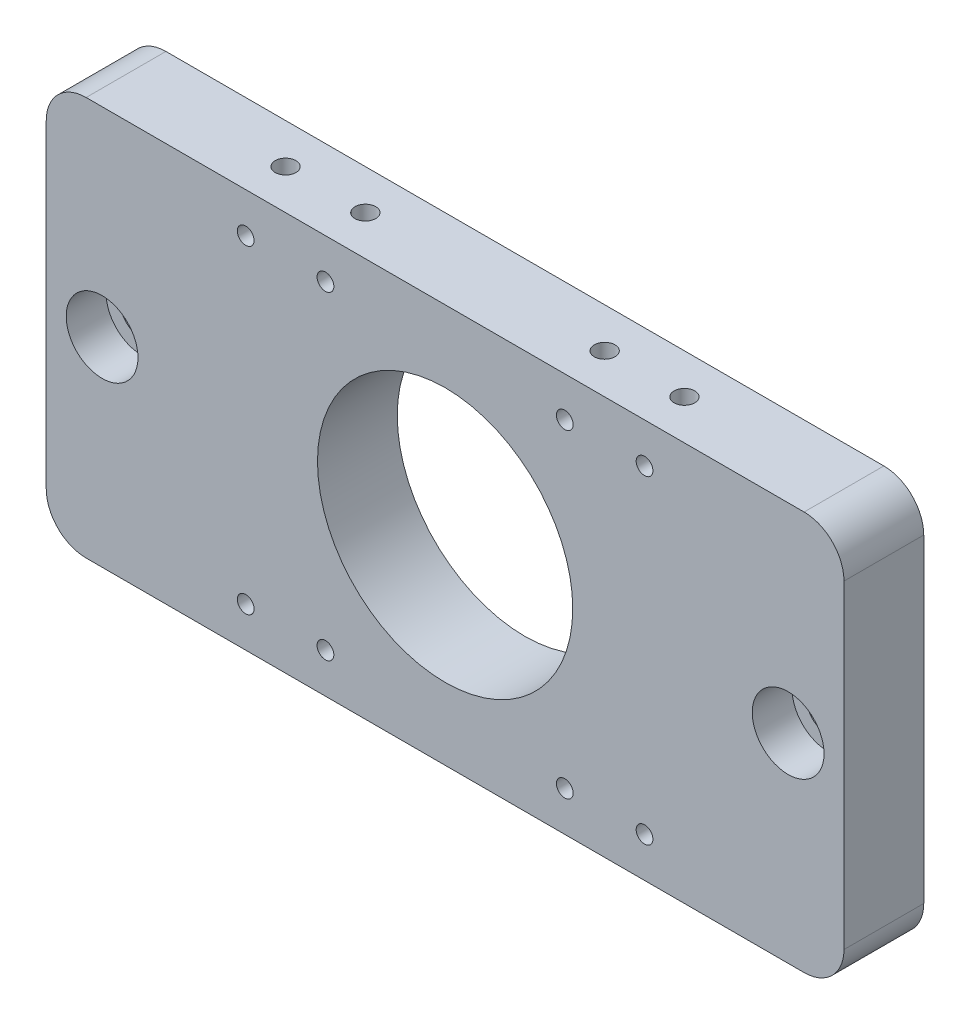
from build123d import *

# Parameters (mm, degrees)
SKETCH1_W           = 100
SKETCH1_H           = 50
SKETCH1_R           = 16
SKETCH1_R_2         = 2.75
BOSS_EXTRUDE1_DEPTH = 10
SKETCH2_R           = 4.5
CUT_EXTRUDE1_DEPTH  = 5
SKETCH3_R           = 1.05
CUT_EXTRUDE2_DEPTH  = 11
SKETCH4_R           = 1.3
CUT_EXTRUDE3_DEPTH  = 10
FILLET1_R           = 5


with BuildPart() as part:
    # Sketch1 → Boss-Extrude1 (new body)
    with BuildSketch(Plane.XY):
        with Locations((50, 25)):
            Rectangle(SKETCH1_W, SKETCH1_H)
        with Locations((50, 25)):
            Circle(SKETCH1_R, mode=Mode.SUBTRACT)
        with Locations((7, 25)):
            Circle(SKETCH1_R_2, mode=Mode.SUBTRACT)
        with Locations((93, 25)):
            Circle(SKETCH1_R_2, mode=Mode.SUBTRACT)
    extrude(amount=BOSS_EXTRUDE1_DEPTH)

    # Sketch2 → Cut-Extrude1 (cut)
    with BuildSketch(Plane.XY.offset(10)):
        with Locations((7, 25)):
            Circle(SKETCH2_R)
        with Locations((93, 25)):
            Circle(SKETCH2_R)
    extrude(amount=-CUT_EXTRUDE1_DEPTH, mode=Mode.SUBTRACT)

    # Sketch3 → Cut-Extrude2 (cut, through all)
    with BuildSketch(Plane.XY.offset(10)):
        with Locations((35, 5)):
            Circle(SKETCH3_R)
        with Locations((25, 5)):
            Circle(SKETCH3_R)
        with Locations((65, 5)):
            Circle(SKETCH3_R)
        with Locations((75, 5)):
            Circle(SKETCH3_R)
        with Locations((25, 45)):
            Circle(SKETCH3_R)
        with Locations((35, 45)):
            Circle(SKETCH3_R)
        with Locations((75, 45)):
            Circle(SKETCH3_R)
        with Locations((65, 45)):
            Circle(SKETCH3_R)
    extrude(amount=-CUT_EXTRUDE2_DEPTH, mode=Mode.SUBTRACT)

    # Sketch4 → Cut-Extrude3 (cut)
    with BuildSketch(Plane.XZ):
        with Locations((35, 5)):
            Circle(SKETCH4_R)
        with Locations((25, 5)):
            Circle(SKETCH4_R)
        with Locations((65, 5)):
            Circle(SKETCH4_R)
        with Locations((75, 5)):
            Circle(SKETCH4_R)
    cut_extrude3 = extrude(amount=-CUT_EXTRUDE3_DEPTH, mode=Mode.SUBTRACT)

    # Mirror1: Cut-Extrude3 across plane
    add(cut_extrude3.mirror(Plane.ZX.offset(25)), mode=Mode.SUBTRACT)

    # Fillet1
    fillet1_edges = [part.edges().sort_by_distance(p)[0] for p in [
        (0, 50, 5),
        (100, 50, 5),
        (100, 0, 5),
        (0, 0, 5),
    ]]
    fillet(fillet1_edges, radius=FILLET1_R)


solid = part.part
